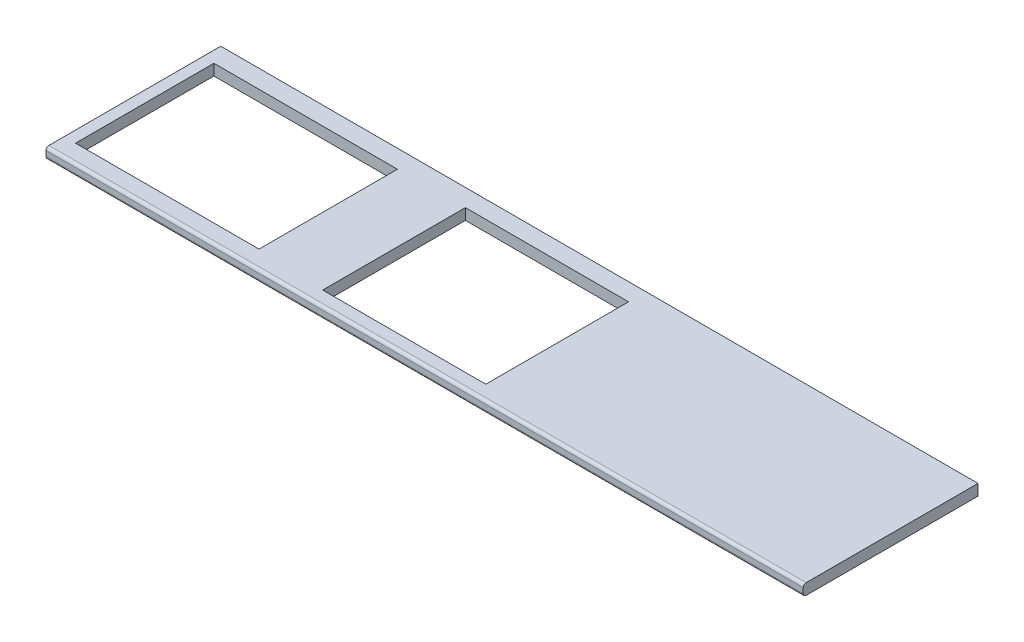
from build123d import *

# Parameters (mm, degrees)
SKETCH_1_W               = 2600
SKETCH_1_H               = 600
EXTRUDE_1_DEPTH          = 38
FILLET_1_R               = 10
SKETCH_2_W               = 560
SKETCH_2_H               = 490
SKETCH_2_W_2             = 630
SKETCH_2_H_2             = 475
CUT_EXTRUDE_1_DEPTH      = 1
CUT_EXTRUDE_1_DEPTH_BACK = 39


with BuildPart() as part:
    # Эскиз1 → Бобышка-Вытянуть1 (new body)
    with BuildSketch(Plane(origin=(0, 0, 0), x_dir=(1, 0, 0), z_dir=(0, 1, 0))):
        Rectangle(SKETCH_1_W, SKETCH_1_H)
    extrude(amount=EXTRUDE_1_DEPTH)

    # Скругление1
    fillet_1_edges = [part.edges().sort_by_distance(p)[0] for p in [
        (0, 0, 300),
        (0, 38, 300),
    ]]
    fillet(fillet_1_edges, radius=FILLET_1_R)

    # Эскиз2 → Вырез-Вытянуть1 (cut, two sides)
    with BuildSketch(Plane(origin=(0, 38, 0), x_dir=(1, 0, 0), z_dir=(0, 1, 0))) as cut_extrude_1_sk:
        with Locations((-120, -5)):
            Rectangle(SKETCH_2_W, SKETCH_2_H)
        with Locations((-946, 0)):
            Rectangle(SKETCH_2_W_2, SKETCH_2_H_2)
    extrude(amount=CUT_EXTRUDE_1_DEPTH, mode=Mode.SUBTRACT)
    extrude(cut_extrude_1_sk.sketch, amount=-CUT_EXTRUDE_1_DEPTH_BACK, mode=Mode.SUBTRACT)


solid = part.part
